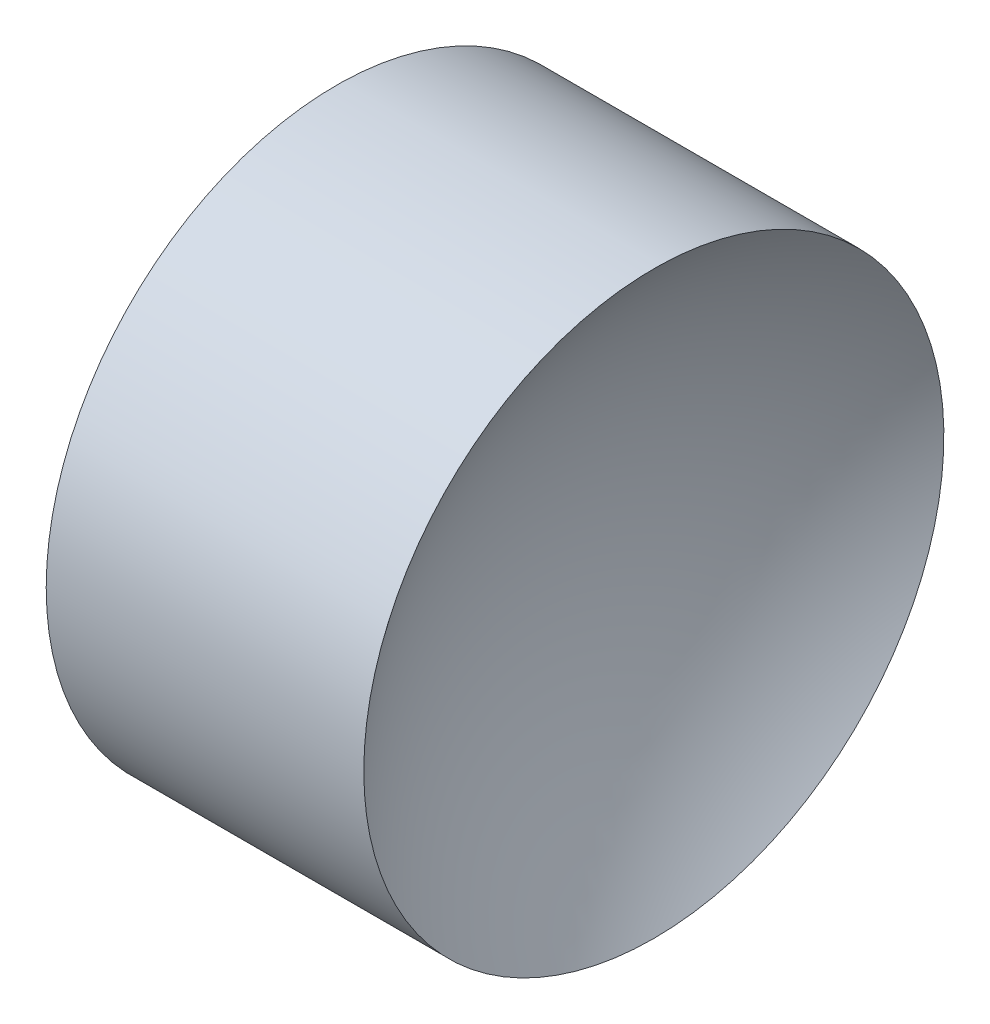
from build123d import *


with BuildPart() as part:
    # 草图1 → 旋转1 (revolve)
    with BuildSketch(Plane.XY, mode=Mode.PRIVATE) as revolve_1_sk:
        with BuildLine():
            Line((11.082863231, 6.522260287), (11.082863231, 8.522260287))
            Line((11.082863231, 8.522260287), (13.272863231, 8.522260287))
            ThreePointArc((13.272863231, 8.522260287), (12.760211695, 7.580100067), (12.582863231, 6.522260287))
            Line((12.582863231, 6.522260287), (11.082863231, 6.522260287))
        make_face()
    revolve(revolve_1_sk.sketch.rotate(Axis((10.612465279, 6.522260287, 0), (1, 0, 0)), 180), axis=Axis((10.612465279, 6.522260287, 0), (1, 0, 0)))  # turned: the seam where the file's is


solid = part.part
